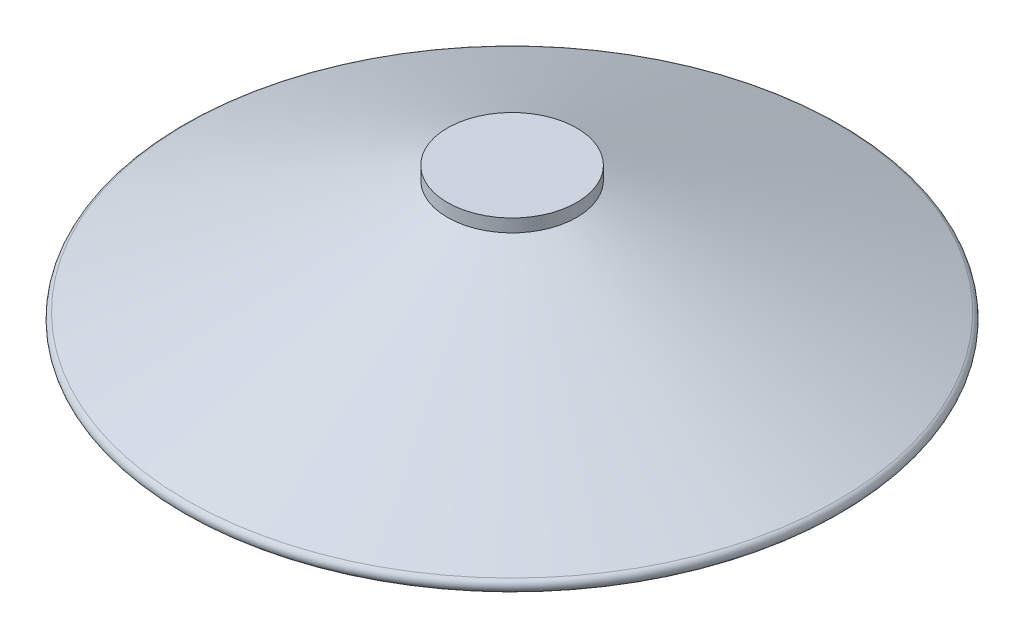
from build123d import *


with BuildPart() as part:
    # Sketch1 → Revolve1 (revolve)
    with BuildSketch(Plane.XY):
        with BuildLine():
            Line((0, 10.8), (-5, 10.8))
            Line((-5, 10.8), (-5, 9.8))
            Line((-5, 9.8), (-25.200490152, 0.958043337))
            ThreePointArc((-25.200490152, 0.958043337), (-25.489398441, 0.397583372), (-25, 0))
            Line((-25, 0), (0, 0))
            Line((0, 0), (0, 10.8))
        make_face()
    revolve(axis=Axis((0, 17.720157406, 0), (0, -1, 0)))


solid = part.part
